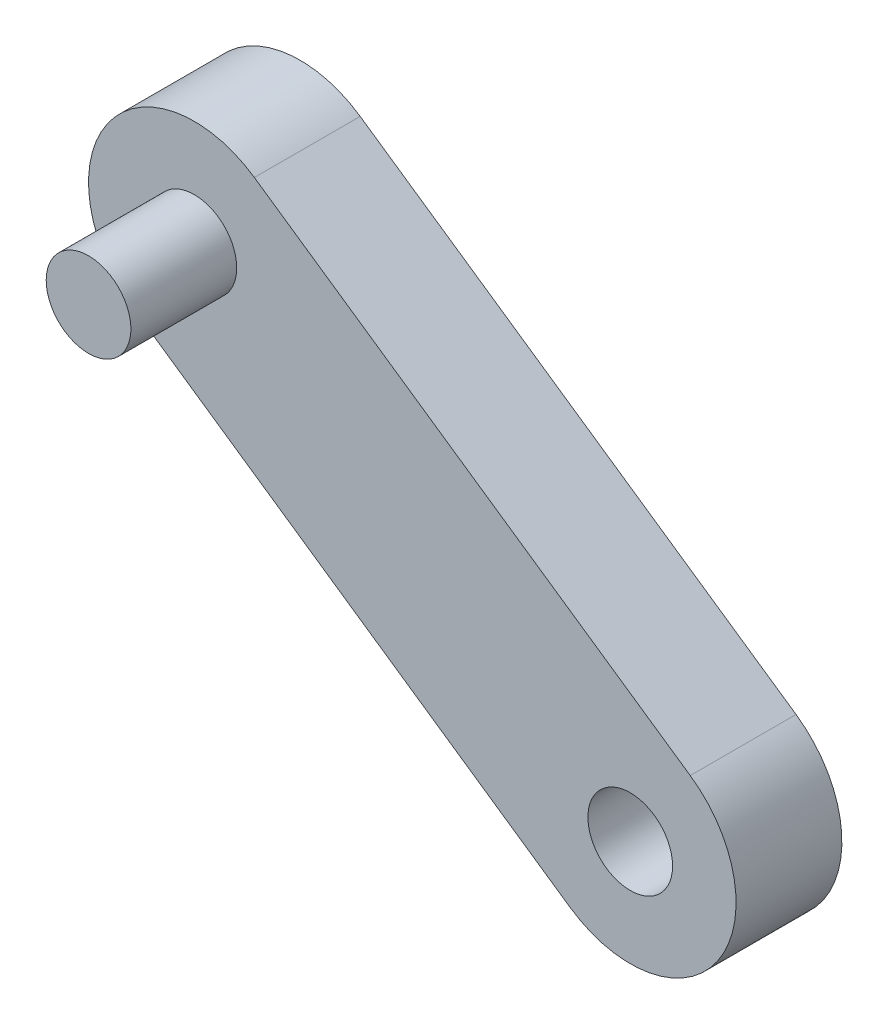
from build123d import *

# Parameters (mm, degrees)
SKETCH1_R           = 2
BOSS_EXTRUDE1_DEPTH = 5
SKETCH2_R           = 2
BOSS_EXTRUDE2_DEPTH = 10


with BuildPart() as part:
    # Sketch1 → Boss-Extrude1 (new body)
    with BuildSketch(Plane(origin=(0, 0, 0), x_dir=(0.999757303, -0.022030336, 0), z_dir=(0, 0, 1))):
        with BuildLine():
            Line((-43.491829272, 87.877240738), (-22.59104637, 74.16019754))
            ThreePointArc((-22.59104637, 74.16019754), (-21.15429843, 67.23663232), (-28.077863649, 65.799884379))
            Line((-28.077863649, 65.799884379), (-48.978646551, 79.516927577))
            ThreePointArc((-48.978646551, 79.516927577), (-50.415394492, 86.440492797), (-43.491829272, 87.877240738))
        make_face()
        with Locations((-25.33445501, 69.980040959)):
            Circle(SKETCH1_R, mode=Mode.SUBTRACT)
        with Locations((-46.235237911, 83.697084158)):
            Circle(SKETCH1_R, mode=Mode.SUBTRACT)
    extrude(amount=BOSS_EXTRUDE1_DEPTH)


with BuildPart() as body_2:
    # Sketch2 → Boss-Extrude2 (new body)
    with BuildSketch(Plane(origin=(0, 0, 0), x_dir=(-1, 0, 0), z_dir=(0, 0, -1))):
        with Locations((44.380141864, 84.695348924)):
            Circle(SKETCH2_R)
    extrude(amount=-BOSS_EXTRUDE2_DEPTH)


solid = Compound([part.part, body_2.part])
